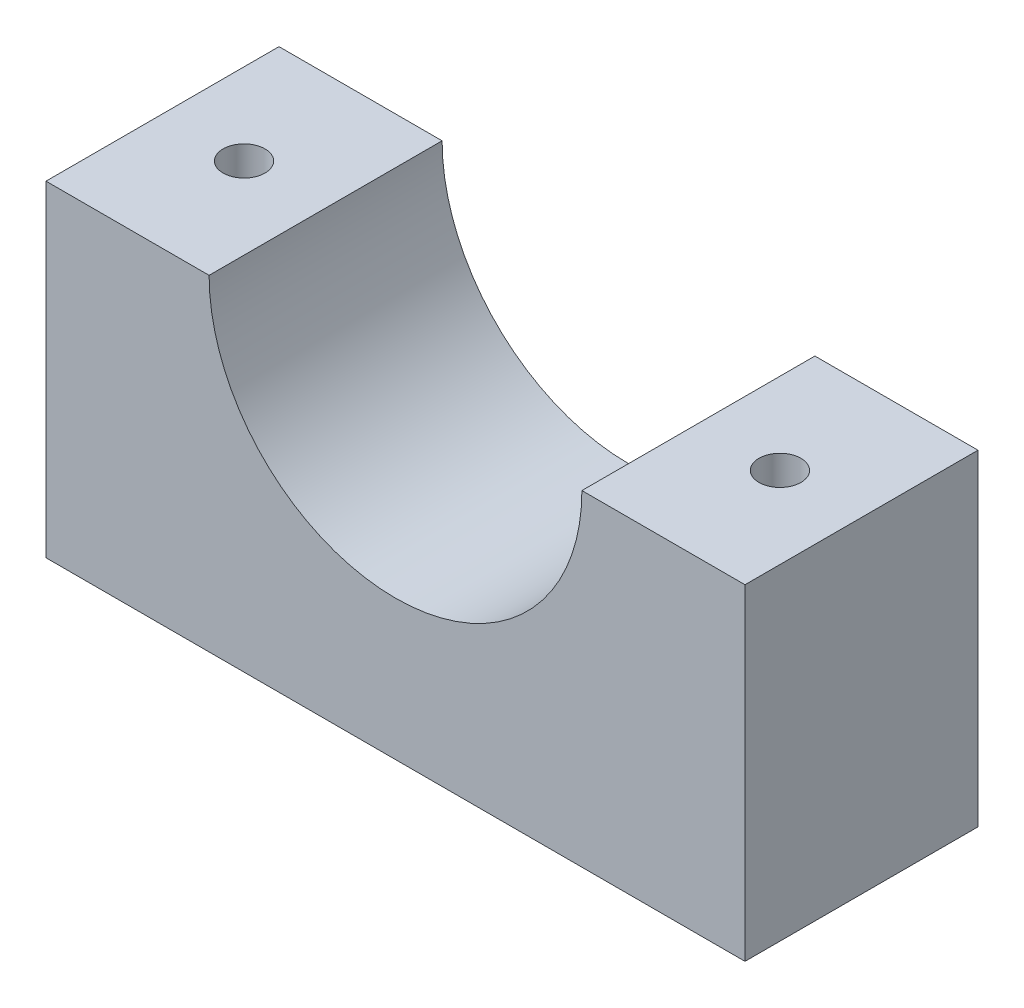
from build123d import *

# Parameters (mm, degrees)
SKETCH1_W           = 38.1
SKETCH1_H           = 17.78
BOSS_EXTRUDE1_DEPTH = 12.7
CUT_EXTRUDE1_DEPTH  = 13.7
CUT_EXTRUDE2_DEPTH  = 18.78


with BuildPart() as part:
    # Sketch1 → Boss-Extrude1 (new body)
    with BuildSketch(Plane.XY):
        with Locations((19.05, -8.89)):
            Rectangle(SKETCH1_W, SKETCH1_H)
    extrude(amount=BOSS_EXTRUDE1_DEPTH)

    # Sketch4 → Cut-Extrude1 (cut, through all)
    with BuildSketch(Plane.XY.offset(12.7)):
        with BuildLine():
            Line((19.05, 0), (29.21, 0))
            ThreePointArc((29.21, 0), (19.05, -10.16), (8.89, 0))
            Line((8.89, 0), (19.05, 0))
        make_face()
    extrude(amount=-CUT_EXTRUDE1_DEPTH, mode=Mode.SUBTRACT)

    # Sketch5 → Cut-Extrude2 (cut, through all)
    with BuildSketch(Plane(origin=(0, 0, 0), x_dir=(1, 0, 0), z_dir=(0, 1, 0))):
        with BuildLine():
            ThreePointArc((5.588, -6.35), (4.445, -5.207), (3.302, -6.35))
            Line((3.302, -6.35), (5.588, -6.35))
        make_face()
        with BuildLine():
            Line((5.588, -6.35), (3.302, -6.35))
            ThreePointArc((3.302, -6.35), (4.445, -7.493), (5.588, -6.35))
        make_face()
        with BuildLine():
            ThreePointArc((32.512, -6.35), (33.655, -7.493), (34.798, -6.35))
            Line((34.798, -6.35), (32.512, -6.35))
        make_face()
        with BuildLine():
            Line((32.512, -6.35), (34.798, -6.35))
            ThreePointArc((34.798, -6.35), (33.655, -5.207), (32.512, -6.35))
        make_face()
    extrude(amount=-CUT_EXTRUDE2_DEPTH, mode=Mode.SUBTRACT)


solid = part.part
